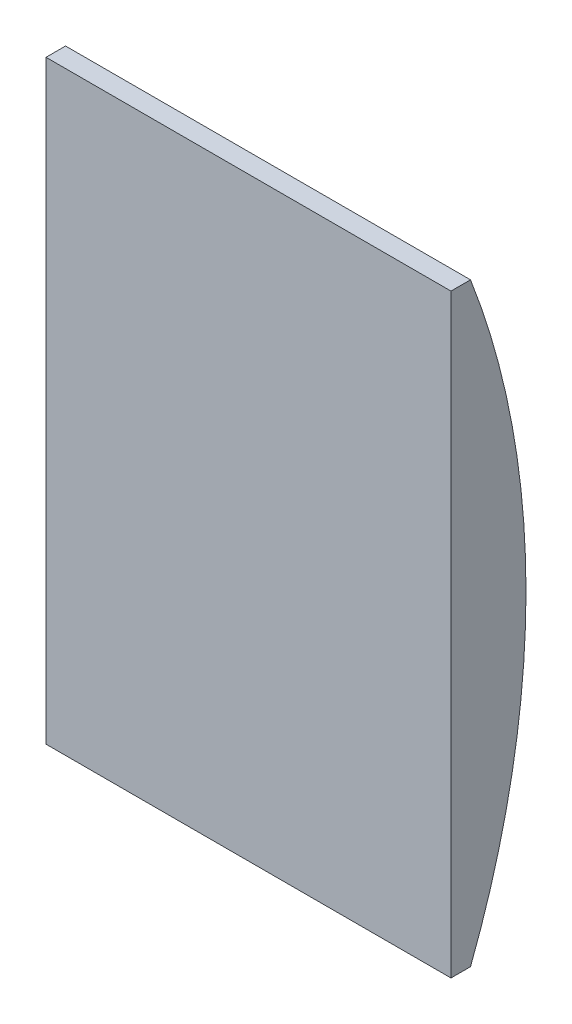
from build123d import *

# Parameters (mm, degrees)
BOSS_EXTRUDE1_DEPTH = 64.5795


with BuildPart() as part:
    # Sketch1 → Boss-Extrude1 (new body)
    with BuildSketch(Plane(origin=(0, 0, 0), x_dir=(0, 0, -1), z_dir=(1, 0, 0))):
        with BuildLine():
            Line((0, 94.869), (3.11404, 94.869))
            ThreePointArc((3.11404, 94.869), (11.96086, 47.4345), (3.11404, 0))
            Line((3.11404, 0), (0, 0))
            Line((0, 0), (0, 94.869))
        make_face()
    extrude(amount=BOSS_EXTRUDE1_DEPTH)


solid = part.part
